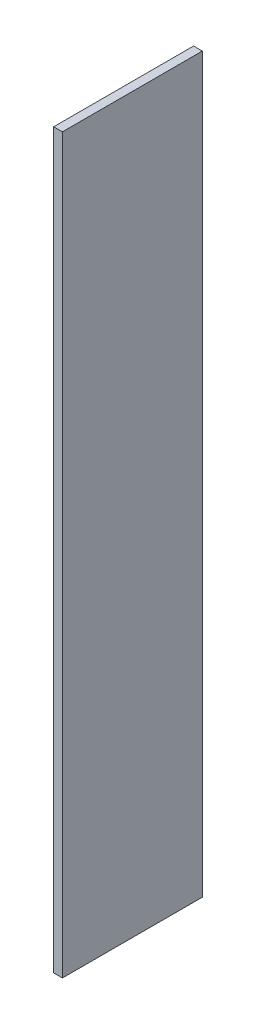
from build123d import *

# Parameters (mm, degrees)
SKETCH1_W           = 6.35
SKETCH1_H           = 532.13
BOSS_EXTRUDE1_DEPTH = 101.6


with BuildPart() as part:
    # Sketch1 → Boss-Extrude1 (new body)
    with BuildSketch(Plane.XY):
        with Locations((3.175, -266.065)):
            Rectangle(SKETCH1_W, SKETCH1_H)
    extrude(amount=BOSS_EXTRUDE1_DEPTH)


solid = part.part
